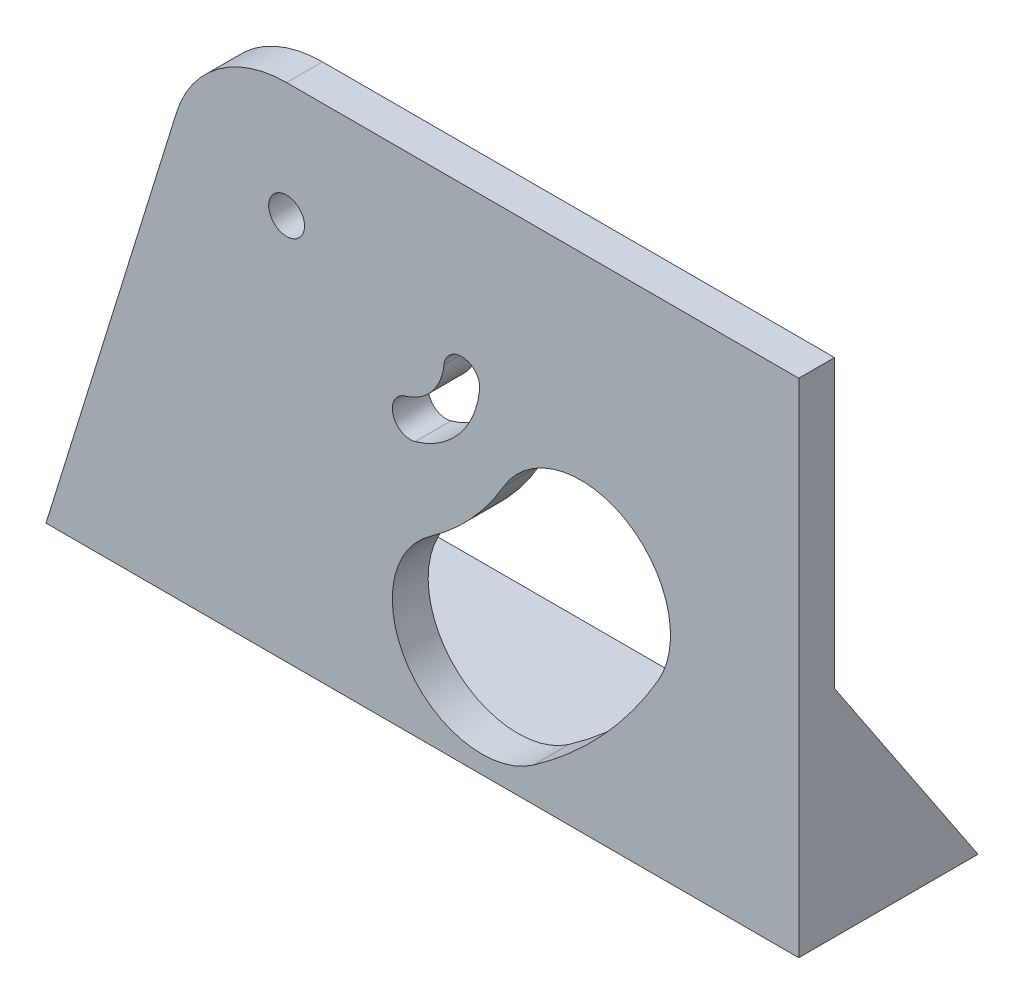
from build123d import *

# Parameters (mm, degrees)
SKETCH1_W           = 120
SKETCH1_H           = 100
BOSS_EXTRUDE1_DEPTH = 5
SKETCH2_R           = 2.5
CUT_EXTRUDE1_DEPTH  = 6
SKETCH3_W           = 120
SKETCH3_H           = 2
BOSS_EXTRUDE2_DEPTH = 20
CUT_EXTRUDE2_DEPTH  = 26
CUT_EXTRUDE3_DEPTH  = 26
SKETCH6_W           = 5
SKETCH6_H           = 30
BOSS_EXTRUDE3_DEPTH = 20
CUT_EXTRUDE4_DEPTH  = 106


with BuildPart() as part:
    # Sketch1 → Boss-Extrude1 (new body)
    with BuildSketch(Plane.XY):
        with Locations((60, 50)):
            Rectangle(SKETCH1_W, SKETCH1_H)
    extrude(amount=BOSS_EXTRUDE1_DEPTH)

    # Sketch2 → Cut-Extrude1 (cut, through all)
    with BuildSketch(Plane.XY.offset(5)):
        with Locations((48.561388608, 53.909722104)):
            Circle(SKETCH2_R)
        with BuildLine():
            ThreePointArc((82.975974789, 4.760599446), (92.719162031, 13.288409394), (100.405906554, 23.707967867))
            ThreePointArc((100.405906554, 23.707967867), (95.896997447, 40.800941239), (78.804024076, 36.292032133))
            ThreePointArc((78.804024076, 36.292032133), (74.320089771, 30.213956356), (68.63656388, 25.239400554))
            ThreePointArc((68.63656388, 25.239400554), (65.566868781, 7.830294546), (82.975974789, 4.760599446))
        make_face()
    extrude(amount=-CUT_EXTRUDE1_DEPTH, mode=Mode.SUBTRACT)

    # Sketch3 → Boss-Extrude2 (add)
    with BuildSketch(Plane(origin=(0, 0, 0), x_dir=(-1, 0, 0), z_dir=(0, 0, -1))):
        with Locations((-60, 1)):
            Rectangle(SKETCH3_W, SKETCH3_H)
    extrude(amount=BOSS_EXTRUDE2_DEPTH)

    # Sketch4 → Cut-Extrude2 (cut, through all)
    with BuildSketch(Plane.XY.offset(5)):
        with BuildLine():
            ThreePointArc((66.494283868, 35.596794606), (72.644903394, 39.60143936), (75.487572744, 46.368013909))
            ThreePointArc((75.487572744, 46.368013909), (73.248961533, 49.104548186), (70.512427256, 46.865936976))
            ThreePointArc((70.512427256, 46.865936976), (68.806825647, 42.805992246), (65.116453931, 40.403205394))
            ThreePointArc((65.116453931, 40.403205394), (63.402163505, 37.311085032), (66.494283868, 35.596794606))
        make_face()
    extrude(amount=-CUT_EXTRUDE2_DEPTH, mode=Mode.SUBTRACT)

    # Sketch5 → Cut-Extrude3 (cut, through all)
    with BuildSketch(Plane.XY.offset(5)):
        with BuildLine():
            Line((120, 70), (48.561388608, 70))
            ThreePointArc((48.561388608, 70), (39.016134462, 66.862913451), (33.192915272, 58.674915711))
            Line((33.192915272, 58.674915711), (15, 0))
            Line((15, 0), (0, 0))
            Line((0, 0), (0, 100))
            Line((0, 100), (120, 100))
            Line((120, 100), (120, 70))
        make_face()
    extrude(amount=-CUT_EXTRUDE3_DEPTH, mode=Mode.SUBTRACT)

    # Sketch6 → Boss-Extrude3 (add, through all)
    with BuildSketch(Plane(origin=(0, 0, 0), x_dir=(-1, 0, 0), z_dir=(0, 0, -1))):
        with Locations((-117.5, 15)):
            Rectangle(SKETCH6_W, SKETCH6_H)
        with Locations((-32.5, 15)):
            Rectangle(SKETCH6_W, SKETCH6_H)
    extrude(amount=BOSS_EXTRUDE3_DEPTH)

    # Sketch9 → Cut-Extrude4 (cut, through all)
    with BuildSketch(Plane(origin=(120, 0, 0), x_dir=(0, 0, -1), z_dir=(1, 0, 0))):
        Polygon((0, 30), (20, 0), (20, 30), align=None)
    extrude(amount=-CUT_EXTRUDE4_DEPTH, mode=Mode.SUBTRACT)


solid = part.part
